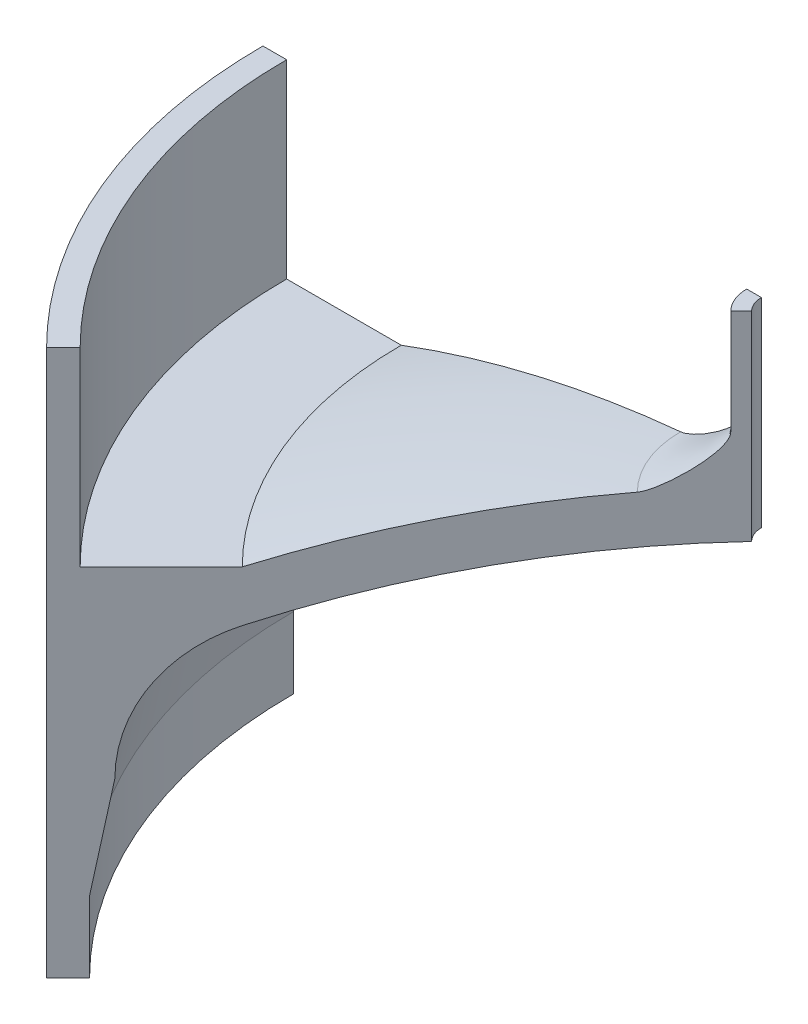
from build123d import *

# Parameters (mm, degrees)
SKETCH2_W          = 97.871859654
SKETCH2_H          = 113.417127273
CUT_REVOLVE1_ANGLE = 315


with BuildPart() as part:
    # Sketch1 → Revolve2 (revolve)
    with BuildSketch(Plane.XY):
        with BuildLine():
            Line((-69.85, 73.025), (-69.85, 10.954807942))
            Line((-69.85, 10.954807942), (-69.85, 0))
            Line((-69.85, 0), (-67.3735, 0))
            Line((-67.3735, 0), (-65.786, 0))
            Line((-65.786, 0), (-65.786, 9.525))
            Line((-65.786, 9.525), (-63.391760989, 23.103404173))
            ThreePointArc((-63.391760989, 23.103404173), (-60.094186985, 33.816180435), (-51.343091672, 40.820172182))
            ThreePointArc((-51.343091672, 40.820172182), (-27.690740484, 47.825337172), (-3.175, 50.561122579))
            Line((-3.175, 50.561122579), (-3.175, 77.231122579))
            Line((-3.175, 77.231122579), (-5.1435, 77.231122579))
            Line((-5.1435, 77.231122579), (-5.1435, 63.261122579))
            add(Edge.make_bspline(
                [(-5.1435, 63.261122579), (-5.1435, 60.992448788), (-11.791391123, 56.487113553), (-13.98475393, 56.276122579)],
                knots=[0, 0, 0, 0, 1, 1, 1, 1], degree=3))
            ThreePointArc((-13.98475393, 56.276122579), (-32.949086986, 53.181992221), (-51.343091672, 47.625))
            Line((-51.343091672, 47.625), (-66.675, 47.625))
            Line((-66.675, 47.625), (-66.675, 73.025))
            Line((-66.675, 73.025), (-69.85, 73.025))
        make_face()
    revolve(axis=Axis((0, 127.060987048, 0), (0, -1, 0)))

    # Sketch2 → Cut-Revolve1 (revolve, cut)
    with BuildSketch(Plane.XY):
        with Locations((-48.935929827, 30.428788157)):
            Rectangle(SKETCH2_W, SKETCH2_H)
    revolve(axis=Axis((0, 127.060987048, 0), (0, -1, 0)), revolution_arc=CUT_REVOLVE1_ANGLE, mode=Mode.SUBTRACT)


solid = part.part
